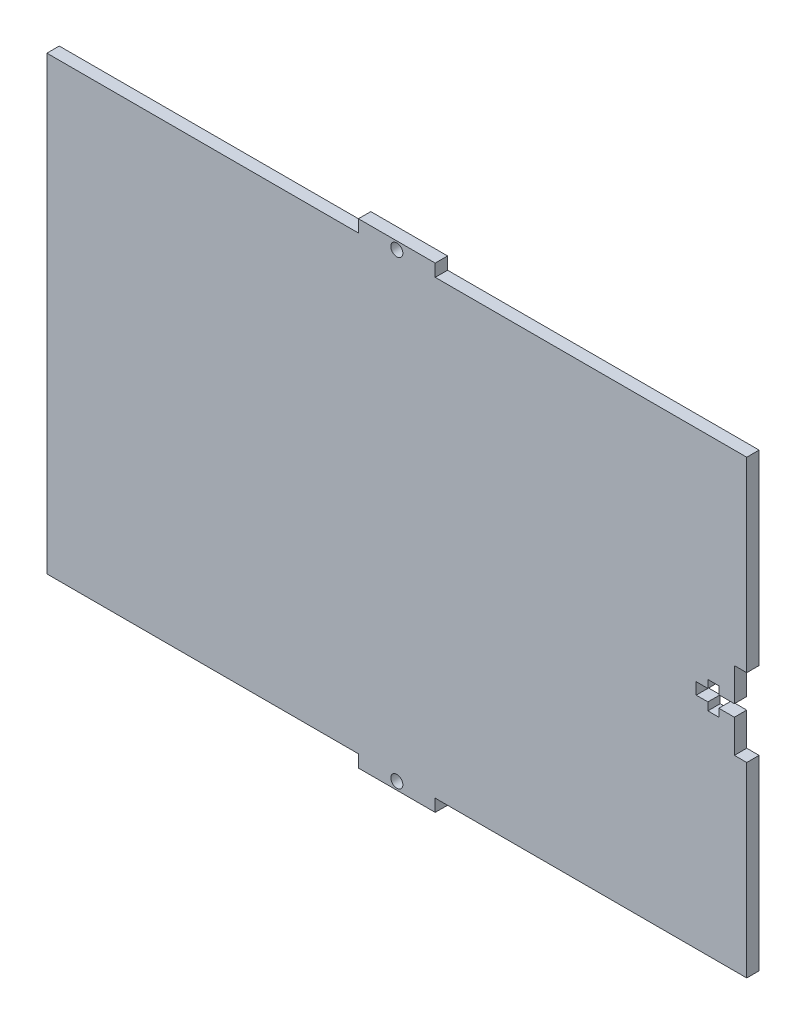
from build123d import *

# Parameters (mm, degrees)
SKETCH1_W               = 180
SKETCH1_H               = 122.36
BOSS_EXTRUDE1_DEPTH     = 3.18
CUT_EXTRUDE1_DEPTH      = 1
CUT_EXTRUDE1_DEPTH_BACK = 4.18
CUT_EXTRUDE2_START      = -4.18
SKETCH3_W               = 80.125
SKETCH3_H               = 3.18
CUT_EXTRUDE2_DEPTH      = 5.18
CUT_EXTRUDE3_START      = -4.18
SKETCH4_R               = 1.55
CUT_EXTRUDE3_DEPTH      = 5.18


with BuildPart() as part:
    # Sketch1 → Boss-Extrude1 (new body)
    with BuildSketch(Plane.XY):
        Rectangle(SKETCH1_W, SKETCH1_H)
    extrude(amount=BOSS_EXTRUDE1_DEPTH)

    # Sketch2 → Cut-Extrude1 (cut, two sides)
    with BuildSketch(Plane.XY.offset(3.18)) as cut_extrude1_sk:
        Polygon((80, 1.5), (77, 1.5), (77, -1.5), (80, -1.5), (80, -3.5), (82.82, -3.5), (82.82, -1.5), (86.82, -1.5), (86.82, -10), (90, -10), (90, 10), (86.82, 10), (86.82, 1.5), (82.82, 1.5), (82.82, 3.5), (80, 3.5), align=None)
    extrude(amount=CUT_EXTRUDE1_DEPTH, mode=Mode.SUBTRACT)
    extrude(cut_extrude1_sk.sketch, amount=-CUT_EXTRUDE1_DEPTH_BACK, mode=Mode.SUBTRACT)

    # Sketch3 → Cut-Extrude2 (cut)
    with BuildSketch(Plane.XY.offset(3.18).offset(CUT_EXTRUDE2_START)):
        with Locations((-49.9375, -59.59)):
            Rectangle(SKETCH3_W, SKETCH3_H)
        with Locations((49.9375, -59.59)):
            Rectangle(SKETCH3_W, SKETCH3_H)
    cut_extrude2 = extrude(amount=CUT_EXTRUDE2_DEPTH, mode=Mode.SUBTRACT)

    # Mirror1: Cut-Extrude2 across plane
    add(cut_extrude2.mirror(Plane.ZX), mode=Mode.SUBTRACT)

    # Sketch4 → Cut-Extrude3 (cut)
    with BuildSketch(Plane.XY.offset(3.18).offset(CUT_EXTRUDE3_START)):
        with Locations((0, -59.18)):
            Circle(SKETCH4_R)
    cut_extrude3 = extrude(amount=CUT_EXTRUDE3_DEPTH, mode=Mode.SUBTRACT)

    # Mirror2: Cut-Extrude3 across plane
    add(cut_extrude3.mirror(Plane.ZX), mode=Mode.SUBTRACT)


solid = part.part
